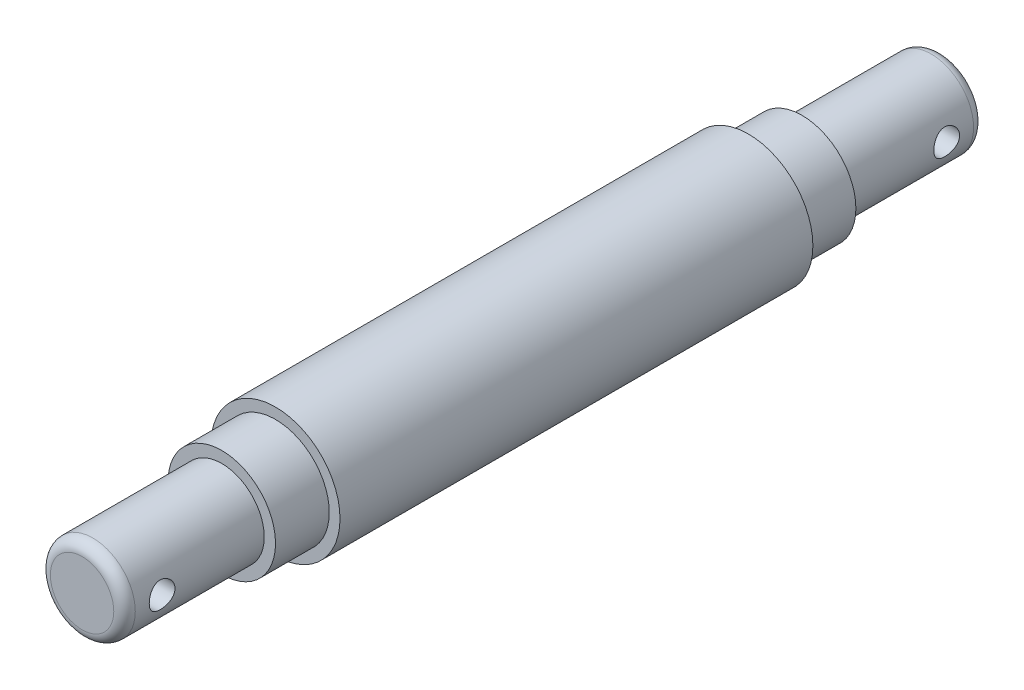
from build123d import *

# Parameters (mm, degrees)
SKETCH1_R           = 3.95
BOSS_EXTRUDE1_DEPTH = 13
SKETCH2_R           = 5
BOSS_EXTRUDE2_DEPTH = 5
SKETCH3_R           = 6
BOSS_EXTRUDE3_DEPTH = 44
SKETCH4_R           = 5
BOSS_EXTRUDE4_DEPTH = 5
SKETCH5_R           = 3.95
BOSS_EXTRUDE5_DEPTH = 13
FILLET1_R           = 1
SKETCH6_R           = 1.2
CUT_EXTRUDE1_DEPTH  = 6.5


with BuildPart() as part:
    # Sketch1 → Boss-Extrude1 (new body)
    with BuildSketch(Plane.XY):
        Circle(SKETCH1_R)
    extrude(amount=BOSS_EXTRUDE1_DEPTH)

    # Sketch2 → Boss-Extrude2 (add)
    with BuildSketch(Plane.XY.offset(13)):
        Circle(SKETCH2_R)
    extrude(amount=BOSS_EXTRUDE2_DEPTH)

    # Sketch3 → Boss-Extrude3 (add)
    with BuildSketch(Plane.XY.offset(18)):
        Circle(SKETCH3_R)
    extrude(amount=BOSS_EXTRUDE3_DEPTH)

    # Sketch4 → Boss-Extrude4 (add)
    with BuildSketch(Plane.XY.offset(62)):
        Circle(SKETCH4_R)
    extrude(amount=BOSS_EXTRUDE4_DEPTH)

    # Sketch5 → Boss-Extrude5 (add)
    with BuildSketch(Plane.XY.offset(67)):
        Circle(SKETCH5_R)
    extrude(amount=BOSS_EXTRUDE5_DEPTH)

    # Fillet1
    fillet1_edges = [part.edges().sort_by_distance(p)[0] for p in [
        (-3.95, 0, 0),
        (-3.95, 0, 80),
    ]]
    fillet(fillet1_edges, radius=FILLET1_R)

    # Sketch6 → Cut-Extrude1 (cut, symmetric)
    with BuildSketch(Plane(origin=(0, 0, 0), x_dir=(0, 0, -1), z_dir=(1, 0, 0))):
        with Locations((-76.5, 0)):
            Circle(SKETCH6_R)
        with Locations((-3.5, 0)):
            Circle(SKETCH6_R)
    extrude(amount=CUT_EXTRUDE1_DEPTH, both=True, mode=Mode.SUBTRACT)


solid = part.part
